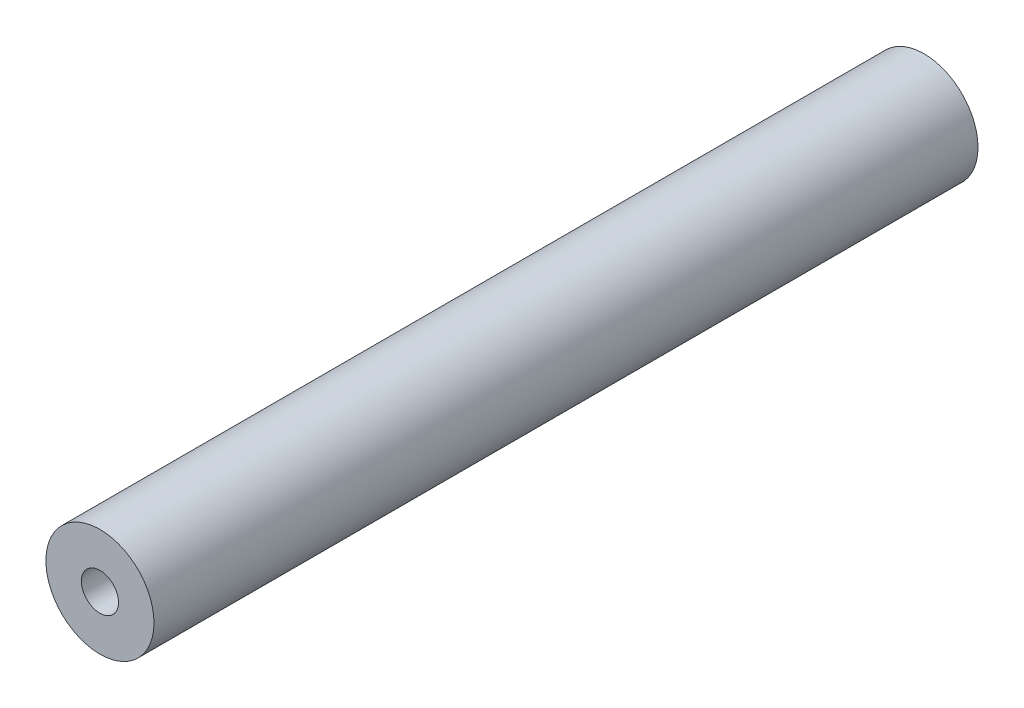
from build123d import *

# Parameters (mm, degrees)
SKETCH1_R           = 4
BOSS_EXTRUDE1_DEPTH = 60.98
SKETCH2_R           = 1.375
CUT_EXTRUDE1_DEPTH  = 61.98


with BuildPart() as part:
    # Sketch1 → Boss-Extrude1 (new body)
    with BuildSketch(Plane.XY):
        Circle(SKETCH1_R)
    extrude(amount=BOSS_EXTRUDE1_DEPTH)

    # Sketch2 → Cut-Extrude1 (cut, through all)
    with BuildSketch(Plane(origin=(0, 0, 0), x_dir=(-1, 0, 0), z_dir=(0, 0, -1))):
        Circle(SKETCH2_R)
    extrude(amount=-CUT_EXTRUDE1_DEPTH, mode=Mode.SUBTRACT)


solid = part.part
